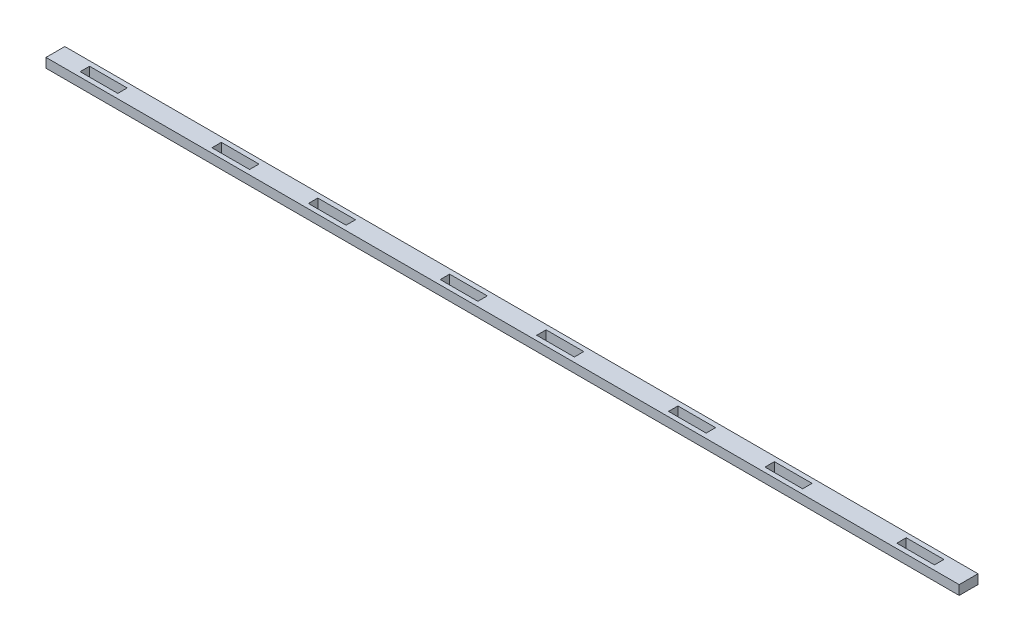
from build123d import *

# Parameters (mm, degrees)
SKETCH1_W           = 615.917267528
SKETCH1_H           = 12.7
BOSS_EXTRUDE1_DEPTH = 6.35
SKETCH2_W           = 25.4
SKETCH2_H           = 6.35
CUT_EXTRUDE1_DEPTH  = 7.35
LPATTERN1_COUNT     = 2
LPATTERN1_PITCH     = 307.958633764
LPATTERN1_COL_COUNT = 2
LPATTERN1_COL_PITCH = 307.958633764


with BuildPart() as part:
    # Sketch1 → Boss-Extrude1 (new body)
    with BuildSketch(Plane(origin=(0, 0, 0), x_dir=(1, 0, 0), z_dir=(0, 1, 0))):
        Rectangle(SKETCH1_W, SKETCH1_H)
    extrude(amount=BOSS_EXTRUDE1_DEPTH)

    # Sketch2 → Cut-Extrude1 (cut, through all)
    with BuildSketch(Plane(origin=(0, 6.35, 0), x_dir=(1, 0, 0), z_dir=(0, 1, 0))):
        with Locations((-32.539658441, 0)):
            Rectangle(SKETCH2_W, SKETCH2_H)
        with Locations((32.539658441, 0)):
            Rectangle(SKETCH2_W, SKETCH2_H)
        with Locations((-121.439658441, 0)):
            Rectangle(SKETCH2_W, SKETCH2_H)
        with Locations((121.439658441, 0)):
            Rectangle(SKETCH2_W, SKETCH2_H)
    cut_extrude1 = extrude(amount=-CUT_EXTRUDE1_DEPTH, mode=Mode.SUBTRACT)

    # LPattern1: Cut-Extrude1 ×2
    with Locations(*[(i * LPATTERN1_PITCH, 0, 0) for i in range(1, LPATTERN1_COUNT)]):
        add(cut_extrude1, mode=Mode.SUBTRACT)

    # LPattern1 col: Cut-Extrude1 ×2
    with Locations(*[(-i * LPATTERN1_COL_PITCH, 0, 0) for i in range(1, LPATTERN1_COL_COUNT)]):
        add(cut_extrude1, mode=Mode.SUBTRACT)


solid = part.part
